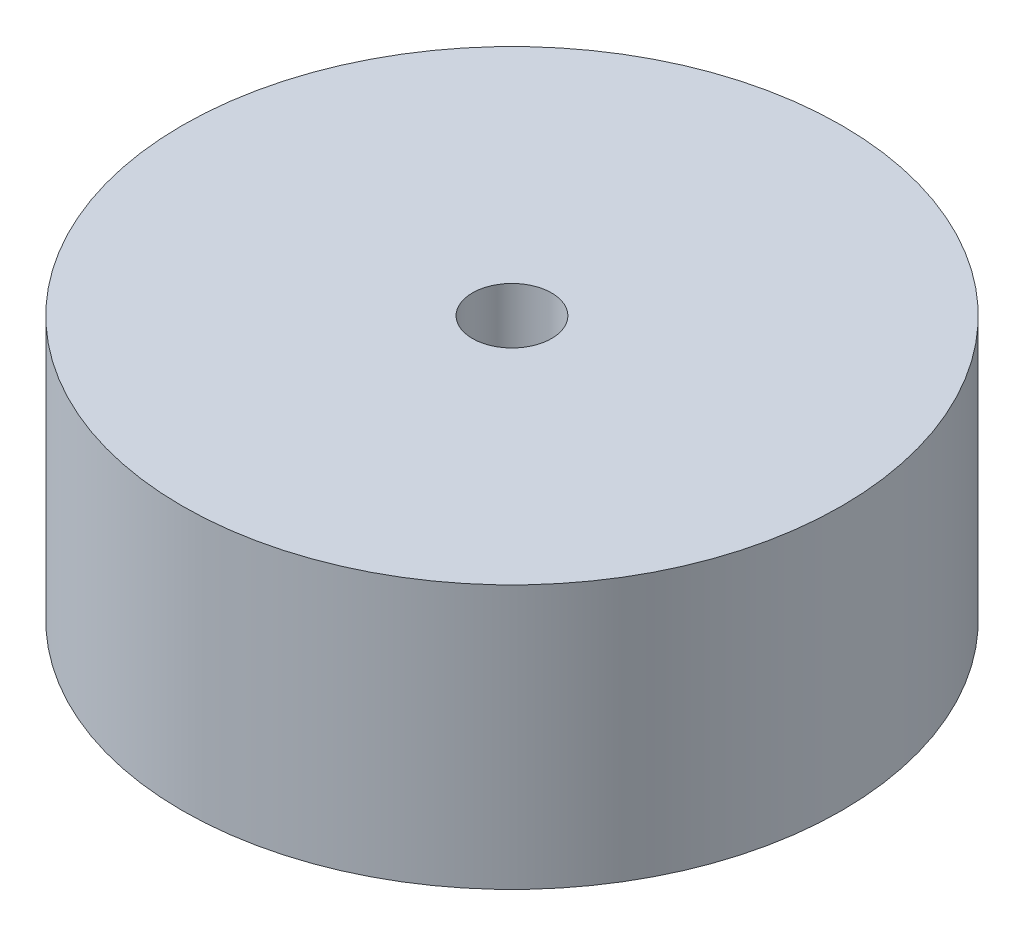
from build123d import *

# Parameters (mm, degrees)
SKETCH1_R           = 25.4
SKETCH1_R_2         = 3.048
BOSS_EXTRUDE1_DEPTH = 20.32


with BuildPart() as part:
    # Sketch1 → Boss-Extrude1 (new body)
    with BuildSketch(Plane(origin=(0, 0, 0), x_dir=(1, 0, 0), z_dir=(0, 1, 0))):
        Circle(SKETCH1_R)
        Circle(SKETCH1_R_2, mode=Mode.SUBTRACT)
    extrude(amount=BOSS_EXTRUDE1_DEPTH)


solid = part.part
